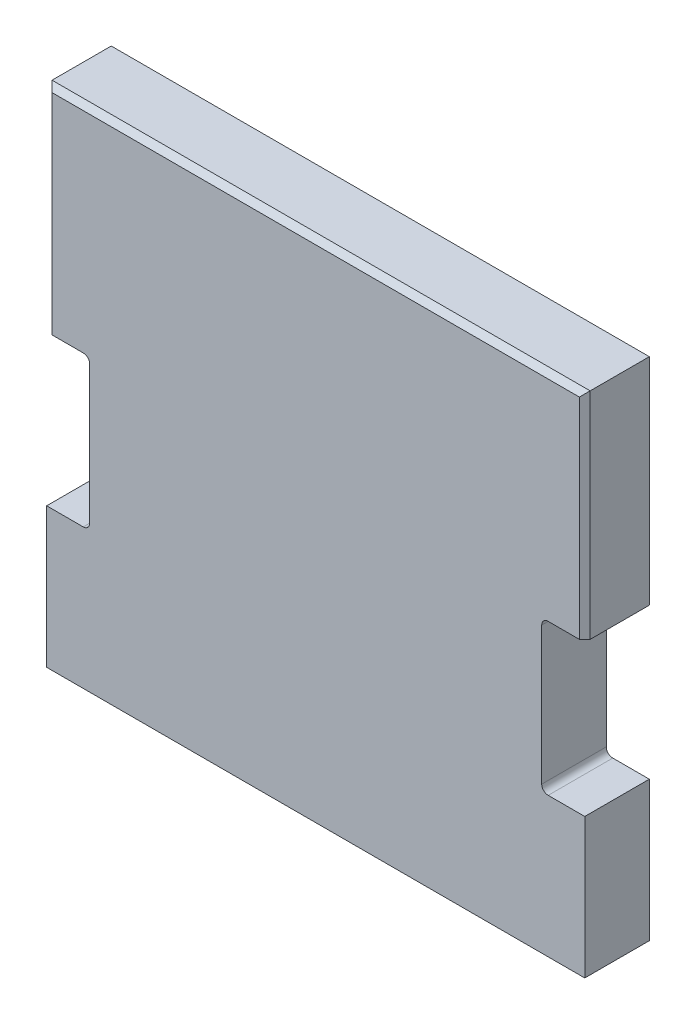
from build123d import *

# Parameters (mm, degrees)
EXTRUDE_1_DEPTH = 3
CHAMFER_1_SIZE  = 0.25


with BuildPart() as part:
    # Эскиз1 → Бобышка-Вытянуть1 (new body)
    with BuildSketch(Plane.XY):
        with BuildLine():
            Line((0, 0), (0, 6.5))
            Line((0, 6.5), (1.7, 6.5))
            ThreePointArc((1.7, 6.5), (1.912132034, 6.587867966), (2, 6.8))
            Line((2, 6.8), (2, 13.2))
            ThreePointArc((2, 13.2), (1.912132034, 13.412132034), (1.7, 13.5))
            Line((1.7, 13.5), (0, 13.5))
            Line((0, 13.5), (0, 23.5))
            Line((0, 23.5), (25, 23.5))
            Line((25, 23.5), (25, 13.5))
            Line((25, 13.5), (23.3, 13.5))
            ThreePointArc((23.3, 13.5), (23.087867966, 13.412132034), (23, 13.2))
            Line((23, 13.2), (23, 6.8))
            ThreePointArc((23, 6.8), (23.087867966, 6.587867966), (23.3, 6.5))
            Line((23.3, 6.5), (25, 6.5))
            Line((25, 6.5), (25, 0))
            Line((25, 0), (0, 0))
        make_face()
    extrude(amount=EXTRUDE_1_DEPTH)

    # Фаска1
    chamfer_1_edges = [part.edges().sort_by_distance(p)[0] for p in [
        (25, 18.5, 3),
        (12.5, 23.5, 3),
        (0, 18.5, 3),
    ]]
    chamfer(chamfer_1_edges, length=CHAMFER_1_SIZE)


solid = part.part
